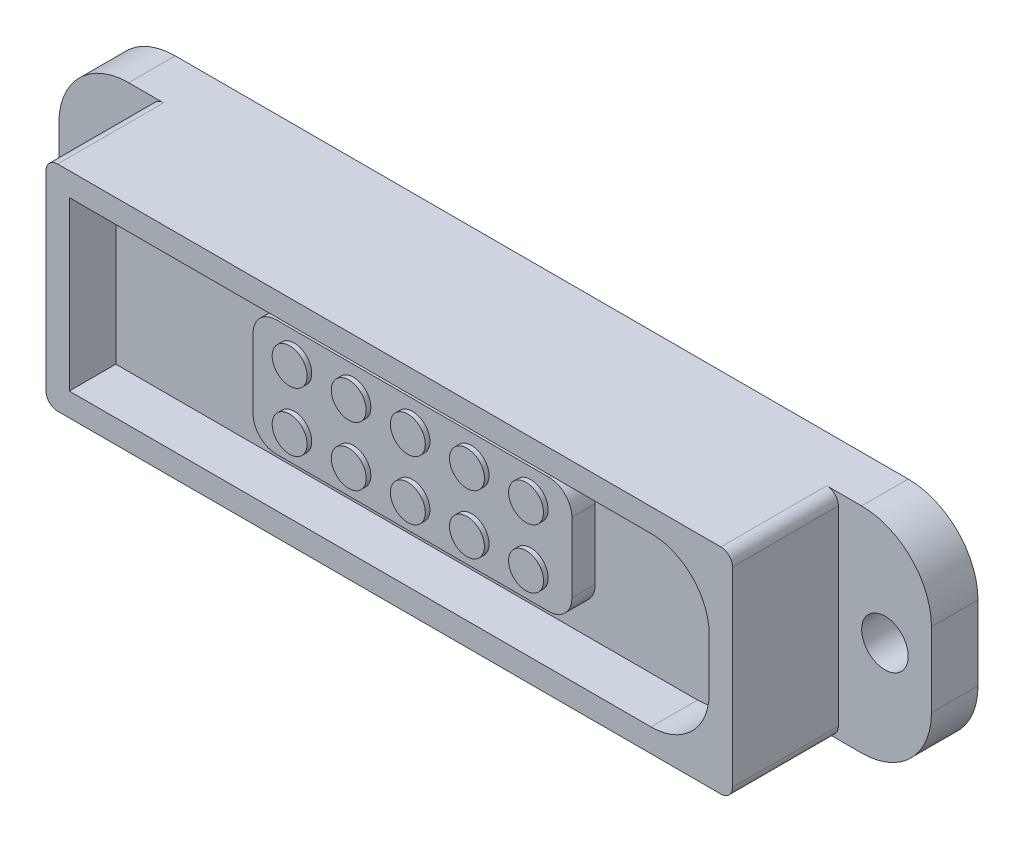
from build123d import *

# Parameters (mm, degrees)
ESQUISSE1_W                     = 37.5
ESQUISSE1_H                     = 9.2
BOSS_EXTRU_1_DEPTH              = 2
CONG_1_R                        = 3
ESQUISSE2_R                     = 1
ENL_V_MAT_EXTRU_1_DEPTH         = 3
ESQUISSE3_W                     = 29.5
ESQUISSE3_H                     = 9.2
BOSS_EXTRU_2_DEPTH              = 4.551597138
CONG_2_R                        = 0.5
ESQUISSE4_W                     = 27.5
ESQUISSE4_H                     = 7.2
ENL_V_MAT_EXTRU_2_DEPTH         = 2
CONG_3_R                        = 2.5
ESQUISSE5_W                     = 13.7
ESQUISSE5_H                     = 5
BOSS_EXTRU_3_DEPTH              = 1
CONG_4_R                        = 1
ESQUISSE6_R                     = 0.75
BOSS_EXTRU_4_DEPTH              = 0.2
BOSS_EXTRU_5_START              = -5.751597
ESQUISSE7_R                     = 0.4
BOSS_EXTRU_5_DEPTH              = 1.758
R_P_TITION_LIN_AIRE1_COUNT      = 2
R_P_TITION_LIN_AIRE1_PITCH      = 2.54
R_P_TITION_LIN_AIRE1_COUNT_DIR2 = 5
R_P_TITION_LIN_AIRE1_PITCH_DIR2 = 2.54


with BuildPart() as part:
    # Esquisse1 → Boss.-Extru.1 (new body)
    with BuildSketch(Plane.XY):
        Rectangle(ESQUISSE1_W, ESQUISSE1_H)
    extrude(amount=BOSS_EXTRU_1_DEPTH)

    # Congé1
    cong_1_edges = [part.edges().sort_by_distance(p)[0] for p in [
        (-18.75, 4.6, 1),
        (18.75, 4.6, 1),
        (18.75, -4.6, 1),
        (-18.75, -4.6, 1),
    ]]
    fillet(cong_1_edges, radius=CONG_1_R)

    # Esquisse2 → Enlèv. mat.-Extru.1 (cut, through all)
    with BuildSketch(Plane.XY.offset(2)):
        with Locations((-16.75, 0)):
            Circle(ESQUISSE2_R)
    enl_v_mat_extru_1 = extrude(amount=-ENL_V_MAT_EXTRU_1_DEPTH, mode=Mode.SUBTRACT)

    # Symétrie1: Enlèv. mat.-Extru.1 across plane
    add(enl_v_mat_extru_1.mirror(Plane(origin=(0, 0, 0), x_dir=(0, 0, 1), z_dir=(1, 0, 0))), mode=Mode.SUBTRACT)

    # Esquisse3 → Boss.-Extru.2 (add)
    with BuildSketch(Plane.XY.offset(2)):
        Rectangle(ESQUISSE3_W, ESQUISSE3_H)
    extrude(amount=BOSS_EXTRU_2_DEPTH)

    # Congé2
    cong_2_edges = [part.edges().sort_by_distance(p)[0] for p in [
        (-14.75, 4.6, 4.275798569),
        (-14.75, -4.6, 4.275798569),
        (14.75, -4.6, 4.275798569),
        (14.75, 4.6, 4.275798569),
    ]]
    fillet(cong_2_edges, radius=CONG_2_R)

    # Esquisse4 → Enlèv. mat.-Extru.2 (cut)
    with BuildSketch(Plane.XY.offset(6.551597138)):
        Rectangle(ESQUISSE4_W, ESQUISSE4_H)
    extrude(amount=-ENL_V_MAT_EXTRU_2_DEPTH, mode=Mode.SUBTRACT)

    # Congé3
    cong_3_edges = [part.edges().sort_by_distance(p)[0] for p in [
        (13.75, 3.6, 5.551597138),
        (13.75, -3.6, 5.551597138),
    ]]
    fillet(cong_3_edges, radius=CONG_3_R)

    # Esquisse5 → Boss.-Extru.3 (add)
    with BuildSketch(Plane.XY.offset(4.551597138)):
        Rectangle(ESQUISSE5_W, ESQUISSE5_H)
    extrude(amount=BOSS_EXTRU_3_DEPTH)

    # Congé4
    cong_4_edges = [part.edges().sort_by_distance(p)[0] for p in [
        (-6.85, 2.5, 5.051597138),
        (-6.85, -2.5, 5.051597138),
        (6.85, -2.5, 5.051597138),
        (6.85, 2.5, 5.051597138),
    ]]
    fillet(cong_4_edges, radius=CONG_4_R)

    # Esquisse6 → Boss.-Extru.4 (add)
    with BuildSketch(Plane.XY.offset(5.551597138)):
        with Locations((-5.08, 1.27)):
            Circle(ESQUISSE6_R)
    boss_extru_4 = extrude(amount=BOSS_EXTRU_4_DEPTH)

    # Esquisse7 → Boss.-Extru.5 (add)
    with BuildSketch(Plane.XY.offset(5.751597138).offset(BOSS_EXTRU_5_START)):
        with Locations((-5.08, 1.27)):
            Circle(ESQUISSE7_R)
    boss_extru_5 = extrude(amount=-BOSS_EXTRU_5_DEPTH)

    # Répétition linéaire1: Boss.-Extru.4, Boss.-Extru.5 2 × 5
    with Locations(*[(j * R_P_TITION_LIN_AIRE1_PITCH_DIR2, -i * R_P_TITION_LIN_AIRE1_PITCH, 0) for i in range(R_P_TITION_LIN_AIRE1_COUNT) for j in range(R_P_TITION_LIN_AIRE1_COUNT_DIR2) if (i, j) != (0, 0)]):
        add(boss_extru_4)
        add(boss_extru_5)


solid = part.part
